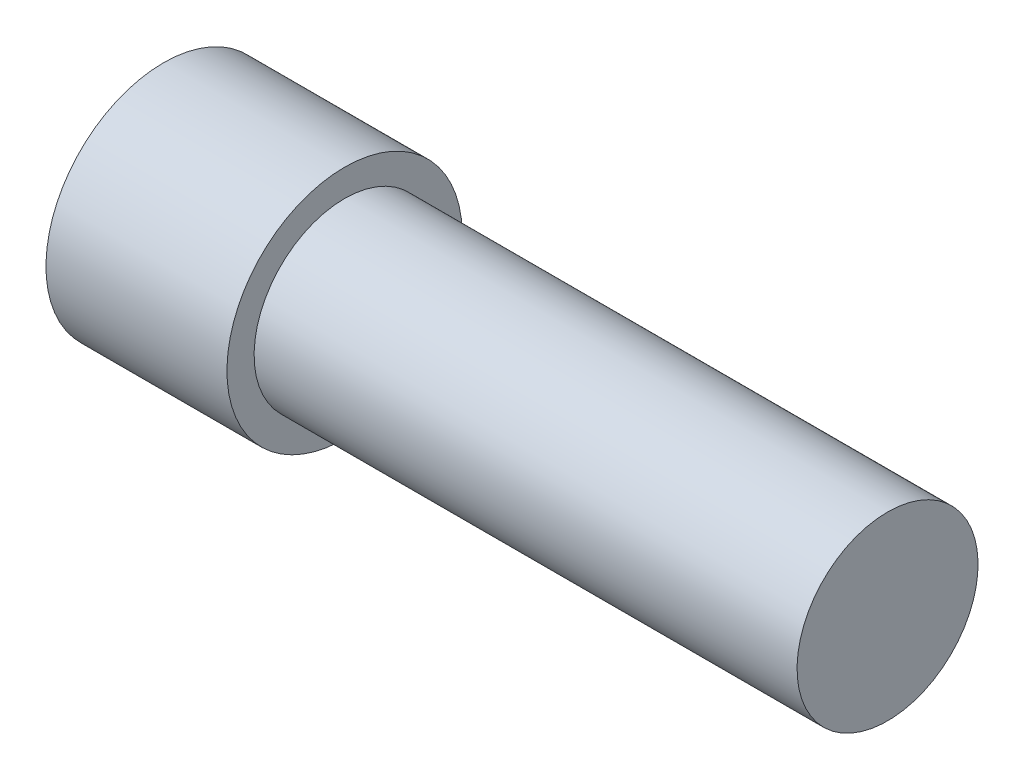
from build123d import *

# Parameters (mm, degrees)
CUT_EXTRUDE1_DEPTH = 9


with BuildPart() as part:
    # Sketch1 → Revolve1 (revolve)
    with BuildSketch(Plane.XY):
        Polygon((-20, 0), (-20, 6.5), (-10, 6.5), (-10, 5), (20, 5), (20, 0), align=None)
    revolve(axis=Axis((20, 0, 0), (-1, 0, 0)))

    # Sketch2 → Cut-Extrude1 (cut)
    with BuildSketch(Plane.ZY.offset(20)):
        Polygon((5.196152423, 0), (2.598076211, 4.5), (-2.598076211, 4.5), (-5.196152423, 0), (-2.598076211, -4.5), (2.598076211, -4.5), align=None)
    extrude(amount=-CUT_EXTRUDE1_DEPTH, mode=Mode.SUBTRACT)


solid = part.part
